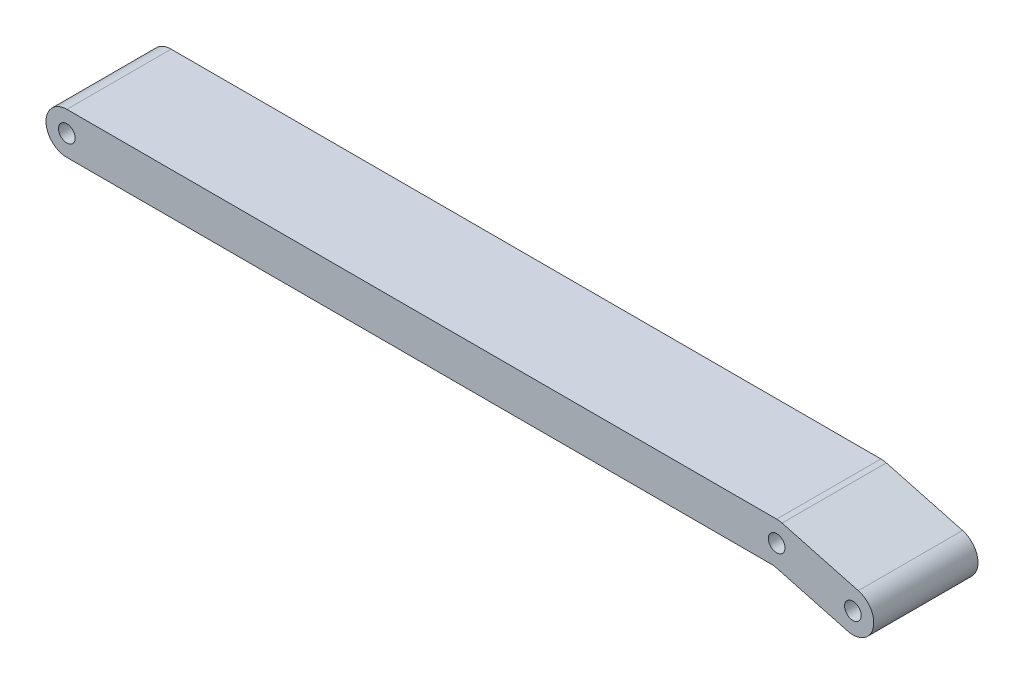
from build123d import *

# Parameters (mm, degrees)
SKETCH1_R           = 4
BOSS_EXTRUDE1_DEPTH = 50


with BuildPart() as part:
    # Sketch1 → Boss-Extrude1 (new body)
    with BuildSketch(Plane.XY):
        with BuildLine():
            Line((94.813332526, 279.2), (130.111538956, 269.740814246))
            ThreePointArc((130.111538956, 269.740814246), (142.359185754, 276.811538956), (135.288461044, 289.059185754))
            Line((135.288461044, 289.059185754), (98.718461044, 298.859185754))
            ThreePointArc((98.718461044, 298.859185754), (97.435400794, 299.11443033), (96.13, 299.2))
            Line((96.13, 299.2), (-244.3, 299.2))
            ThreePointArc((-244.3, 299.2), (-254.3, 289.2), (-244.3, 279.2))
            Line((-244.3, 279.2), (94.813332526, 279.2))
        make_face()
        with Locations((96.13, 289.2)):
            Circle(SKETCH1_R, mode=Mode.SUBTRACT)
        with Locations((132.7, 279.4)):
            Circle(SKETCH1_R, mode=Mode.SUBTRACT)
        with Locations((-244.3, 289.2)):
            Circle(SKETCH1_R, mode=Mode.SUBTRACT)
    extrude(amount=BOSS_EXTRUDE1_DEPTH)


solid = part.part
